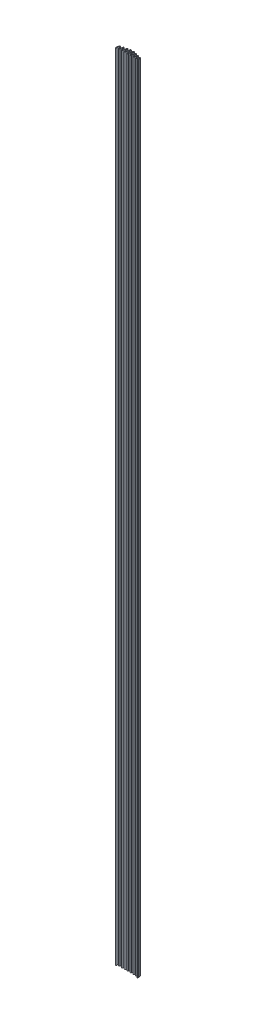
from build123d import *

# Parameters (mm, degrees)
BOSS_EXTRUDE1_DEPTH = 3505.2
CUT_EXTRUDE1_DEPTH  = 3506.2
BOSS_EXTRUDE2_DEPTH = 3505.2
FILLET1_R           = 0.508


with BuildPart() as part:
    # Sketch1 → Boss-Extrude1 (new body)
    with BuildSketch(Plane(origin=(0, 0, 0), x_dir=(1, 0, 0), z_dir=(0, 1, 0))):
        with BuildLine():
            Line((1.540485976, 1.167137652), (3.904784165, 9.577400553))
            ThreePointArc((3.904784165, 9.577400553), (6.35, 11.43), (8.795215835, 9.577400553))
            Line((8.795215835, 9.577400553), (11.159514024, 1.167137652))
            ThreePointArc((11.159514024, 1.167137652), (12.767277455, 0.001414904), (14.271422384, 1.298087881))
            Line((14.271422384, 1.298087881), (16.555678756, 13.179543046))
            ThreePointArc((16.555678756, 13.179543046), (19.05, 15.24), (21.544321244, 13.179543046))
            Line((21.544321244, 13.179543046), (23.828577616, 1.298087881))
            ThreePointArc((23.828577616, 1.298087881), (25.436521885, 0.00041683), (26.983572077, 1.370114107))
            Line((26.983572077, 1.370114107), (29.236393529, 16.875215703))
            ThreePointArc((29.236393529, 16.875215703), (31.75, 19.05), (34.263606471, 16.875215703))
            Line((34.263606471, 16.875215703), (36.516427923, 1.370114107))
            ThreePointArc((36.516427923, 1.370114107), (38.116106242, 8.1058e-05), (39.687882683, 1.40203687))
            Line((39.687882683, 1.40203687), (41.929551297, 19.364544652))
            ThreePointArc((41.929551297, 19.364544652), (44.45, 21.59), (46.970448703, 19.364544652))
            Line((46.970448703, 19.364544652), (49.212117317, 1.40203687))
            ThreePointArc((49.212117317, 1.40203687), (50.8, 0), (52.387882683, 1.40203687))
            Line((52.387882683, 1.40203687), (54.629551297, 19.364544652))
            ThreePointArc((54.629551297, 19.364544652), (57.15, 21.59), (59.670448703, 19.364544652))
            Line((59.670448703, 19.364544652), (61.912117317, 1.40203687))
            ThreePointArc((61.912117317, 1.40203687), (63.483893758, 8.1058e-05), (65.083572077, 1.370114107))
            Line((65.083572077, 1.370114107), (67.336393529, 16.875215703))
            ThreePointArc((67.336393529, 16.875215703), (69.85, 19.05), (72.363606471, 16.875215703))
            Line((72.363606471, 16.875215703), (74.616427923, 1.370114107))
            ThreePointArc((74.616427923, 1.370114107), (76.163478115, 0.00041683), (77.771422384, 1.298087881))
            Line((77.771422384, 1.298087881), (80.055678756, 13.179543046))
            ThreePointArc((80.055678756, 13.179543046), (82.55, 15.24), (85.044321244, 13.179543046))
            Line((85.044321244, 13.179543046), (87.328577616, 1.298087881))
            ThreePointArc((87.328577616, 1.298087881), (88.832722545, 0.001414904), (90.440485976, 1.167137652))
            Line((90.440485976, 1.167137652), (92.804784165, 9.577400553))
            ThreePointArc((92.804784165, 9.577400553), (95.25, 11.43), (97.695215835, 9.577400553))
            Line((97.695215835, 9.577400553), (100.059514024, 1.167137652))
            ThreePointArc((100.059514024, 1.167137652), (100.633652839, 0.324734122), (101.6, 0))
            Line((101.6, 0), (101.6, -1.524))
            ThreePointArc((101.6, -1.524), (99.71332221, -0.889995285), (98.592384523, 0.75469732))
            Line((98.592384523, 0.75469732), (96.228086334, 9.164960221))
            ThreePointArc((96.228086334, 9.164960221), (95.25, 9.906), (94.271913666, 9.164960221))
            Line((94.271913666, 9.164960221), (91.907615477, 0.75469732))
            ThreePointArc((91.907615477, 0.75469732), (88.768648778, -1.521237569), (85.83198487, 1.010362054))
            Line((85.83198487, 1.010362054), (83.547728498, 12.891817218))
            ThreePointArc((83.547728498, 12.891817218), (82.55, 13.716), (81.552271502, 12.891817218))
            Line((81.552271502, 12.891817218), (79.26801513, 1.010362054))
            ThreePointArc((79.26801513, 1.010362054), (76.128695368, -1.52318619), (73.108264041, 1.150984685))
            Line((73.108264041, 1.150984685), (70.855442588, 16.656086281))
            ThreePointArc((70.855442588, 16.656086281), (69.85, 17.526), (68.844557412, 16.656086281))
            Line((68.844557412, 16.656086281), (66.591735959, 1.150984685))
            ThreePointArc((66.591735959, 1.150984685), (63.468554481, -1.523841744), (60.399848096, 1.213310079))
            Line((60.399848096, 1.213310079), (58.158179481, 19.175817861))
            ThreePointArc((58.158179481, 19.175817861), (57.15, 20.066), (56.141820519, 19.175817861))
            Line((56.141820519, 19.175817861), (53.900151904, 1.213310079))
            ThreePointArc((53.900151904, 1.213310079), (50.8, -1.524), (47.699848096, 1.213310079))
            Line((47.699848096, 1.213310079), (45.458179481, 19.175817861))
            ThreePointArc((45.458179481, 19.175817861), (44.45, 20.066), (43.441820519, 19.175817861))
            Line((43.441820519, 19.175817861), (41.200151904, 1.213310079))
            ThreePointArc((41.200151904, 1.213310079), (38.131445519, -1.523841744), (35.008264041, 1.150984685))
            Line((35.008264041, 1.150984685), (32.755442588, 16.656086281))
            ThreePointArc((32.755442588, 16.656086281), (31.75, 17.526), (30.744557412, 16.656086281))
            Line((30.744557412, 16.656086281), (28.491735959, 1.150984685))
            ThreePointArc((28.491735959, 1.150984685), (25.471304632, -1.52318619), (22.33198487, 1.010362054))
            Line((22.33198487, 1.010362054), (20.047728498, 12.891817218))
            ThreePointArc((20.047728498, 12.891817218), (19.05, 13.716), (18.052271502, 12.891817218))
            Line((18.052271502, 12.891817218), (15.76801513, 1.010362054))
            ThreePointArc((15.76801513, 1.010362054), (12.831351222, -1.521237569), (9.692384523, 0.75469732))
            Line((9.692384523, 0.75469732), (7.328086334, 9.164960221))
            ThreePointArc((7.328086334, 9.164960221), (6.35, 9.906), (5.371913666, 9.164960221))
            Line((5.371913666, 9.164960221), (3.007615477, 0.75469732))
            ThreePointArc((3.007615477, 0.75469732), (1.88667779, -0.889995285), (0, -1.524))
            Line((0, -1.524), (0, 0))
            ThreePointArc((0, 0), (0.966347161, 0.324734122), (1.540485976, 1.167137652))
        make_face()
    extrude(amount=-BOSS_EXTRUDE1_DEPTH)

    # Sketch2 → Cut-Extrude1 (cut, through all)
    with BuildSketch(Plane(origin=(0, 0, 0), x_dir=(1, 0, 0), z_dir=(0, 1, 0))):
        Polygon((0, -0.762), (0, -1.524), (0.277345319, -1.524), align=None)
        Polygon((101.6, -0.762), (101.6, -1.524), (101.322654681, -1.524), align=None)
    extrude(amount=-CUT_EXTRUDE1_DEPTH, mode=Mode.SUBTRACT)

    # Sketch3 → Boss-Extrude2 (add, through all)
    with BuildSketch(Plane(origin=(0, 0, 0), x_dir=(1, 0, 0), z_dir=(0, 1, 0))):
        with BuildLine():
            Line((101.253318352, -1.7145), (101.327004192, -1.512049818))
            ThreePointArc((101.327004192, -1.512049818), (99.638578579, -0.831558962), (98.61607894, 0.674543074))
            ThreePointArc((98.61607894, 0.674543074), (98.556259483, 0.082078125), (98.088520228, -0.286450128))
            ThreePointArc((98.088520228, -0.286450128), (96.202609275, -3.74439965), (99.733973274, -5.488975049))
            ThreePointArc((99.733973274, -5.488975049), (99.873585853, -5.400370737), (99.96251152, -5.260962624))
            Line((99.96251152, -5.260962624), (100.188956675, -4.638809675))
            ThreePointArc((100.188956675, -4.638809675), (100.143030715, -4.289967378), (99.830933786, -4.1275))
            Line((99.830933786, -4.1275), (98.806, -4.1275))
            ThreePointArc((98.806, -4.1275), (97.5995, -2.921), (98.806, -1.7145))
            Line((98.806, -1.7145), (101.253318352, -1.7145))
        make_face()
        with BuildLine():
            Line((1.63748848, -5.260962624), (1.411043325, -4.638809675))
            ThreePointArc((1.411043325, -4.638809675), (1.456969285, -4.289967378), (1.769066214, -4.1275))
            Line((1.769066214, -4.1275), (2.794, -4.1275))
            ThreePointArc((2.794, -4.1275), (4.0005, -2.921), (2.794, -1.7145))
            Line((2.794, -1.7145), (0.346681648, -1.7145))
            Line((0.346681648, -1.7145), (0.272995808, -1.512049818))
            ThreePointArc((0.272995808, -1.512049818), (1.961421421, -0.831558962), (2.98392106, 0.674543074))
            ThreePointArc((2.98392106, 0.674543074), (3.043740517, 0.082078125), (3.511479772, -0.286450128))
            ThreePointArc((3.511479772, -0.286450128), (5.397390725, -3.74439965), (1.866026726, -5.488975049))
            ThreePointArc((1.866026726, -5.488975049), (1.726414147, -5.400370737), (1.63748848, -5.260962624))
        make_face()
    extrude(amount=-BOSS_EXTRUDE2_DEPTH)

    # Fillet1
    fillet1_edges = [part.edges().sort_by_distance(p)[0] for p in [
        (0.346681648, -1752.6, 1.7145),
        (101.253318352, -1752.6, 1.7145),
    ]]
    fillet(fillet1_edges, radius=FILLET1_R)


solid = part.part
